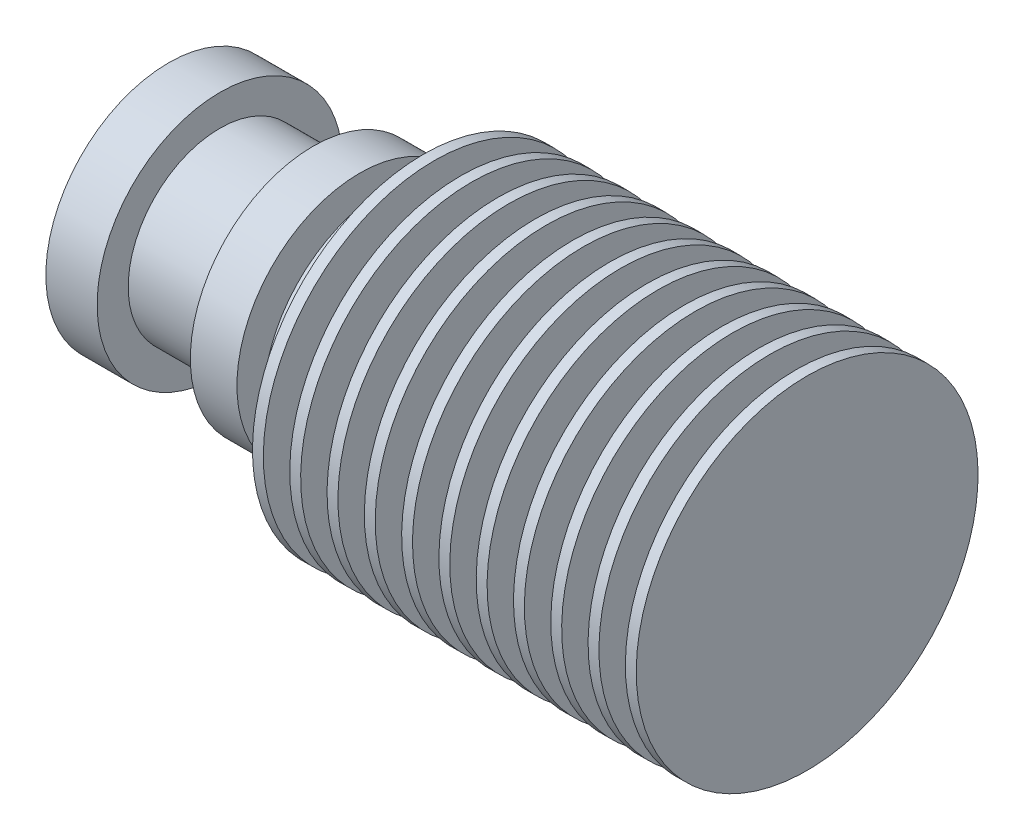
from build123d import *

# Parameters (mm, degrees)
SKETCH1_R          = 3.5
CUT_EXTRUDE1_DEPTH = 10


with BuildPart() as part:
    # Esboço1 → Revolução1 (revolve)
    with BuildSketch(Plane.XY):
        Polygon((-27.999975, 5), (-27.999975, 16), (-28.699975, 16), (-28.699975, 10), (-30.399975, 10), (-30.399975, 16), (-31.099975, 16), (-31.099975, 10), (-32.799975, 10), (-32.799975, 16), (-33.499975, 16), (-33.499975, 10), (-35.199975, 10), (-35.199975, 16), (-35.899975, 16), (-35.899975, 10), (-37.599975, 10), (-37.599975, 16), (-38.299975, 16), (-38.299975, 10), (-39.999975, 10), (-39.999975, 16), (-40.699975, 16), (-40.699975, 10), (-42.399975, 10), (-42.399975, 16), (-43.099975, 16), (-43.099975, 10), (-44.799975, 10), (-44.799975, 16), (-45.499975, 16), (-45.499975, 10), (-47.199975, 10), (-47.199975, 16), (-47.899975, 16), (-47.899975, 10), (-49.599975, 10), (-49.599975, 16), (-50.299975, 16), (-50.299975, 10), (-51.999975, 10), (-51.999975, 16), (-52.699975, 16), (-52.699975, 10), (-54.399975, 10), (-54.399975, 12.9), (-55.099975, 12.9), (-55.099975, 10), (-56.799975, 10), (-56.799975, 12.9), (-59.799975, 12.9), (-59.799975, 10.9), (-65.799975, 10.9), (-65.799975, 12.9), (-69.099975, 12.9), (-69.099975, 5), align=None)
    revolve(axis=Axis((-27.999975, 5, 0), (-1, 0, 0)))

    # Sketch1 → Cut-Extrude1 (cut)
    with BuildSketch(Plane.ZY.offset(69.099975)):
        with Locations((0, 5)):
            Circle(SKETCH1_R)
    extrude(amount=-CUT_EXTRUDE1_DEPTH, mode=Mode.SUBTRACT)


solid = part.part
